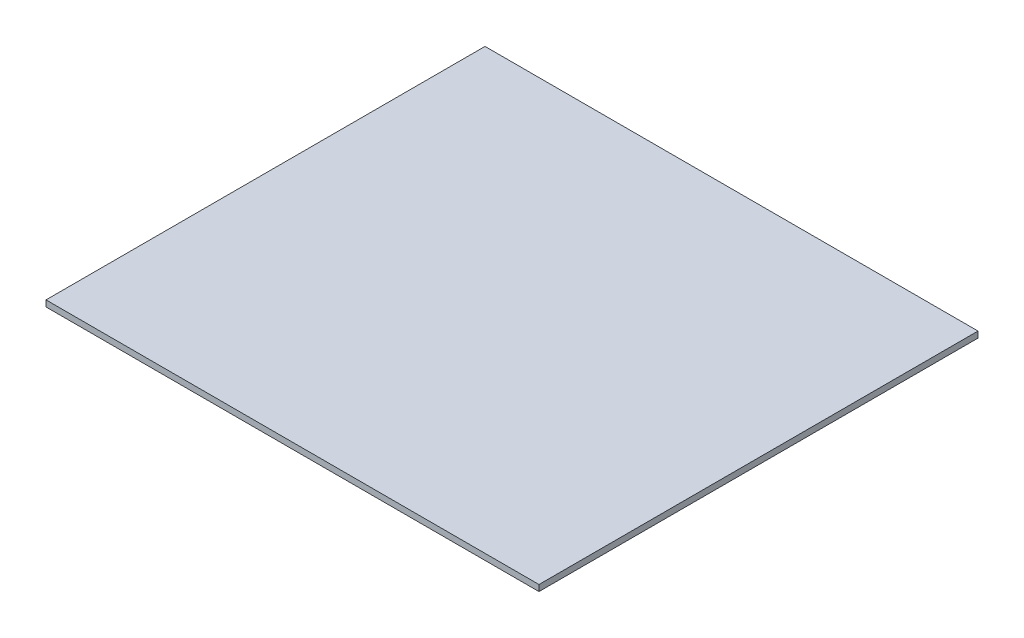
from build123d import *

# Parameters (mm, degrees)
SKETCH1_W           = 128.35
SKETCH1_H           = 114.3
BOSS_EXTRUDE1_DEPTH = 1.6


with BuildPart() as part:
    # Sketch1 → Boss-Extrude1 (new body)
    with BuildSketch(Plane(origin=(0, 0, 0), x_dir=(1, 0, 0), z_dir=(0, 1, 0))):
        Rectangle(SKETCH1_W, SKETCH1_H)
    extrude(amount=BOSS_EXTRUDE1_DEPTH)


solid = part.part
